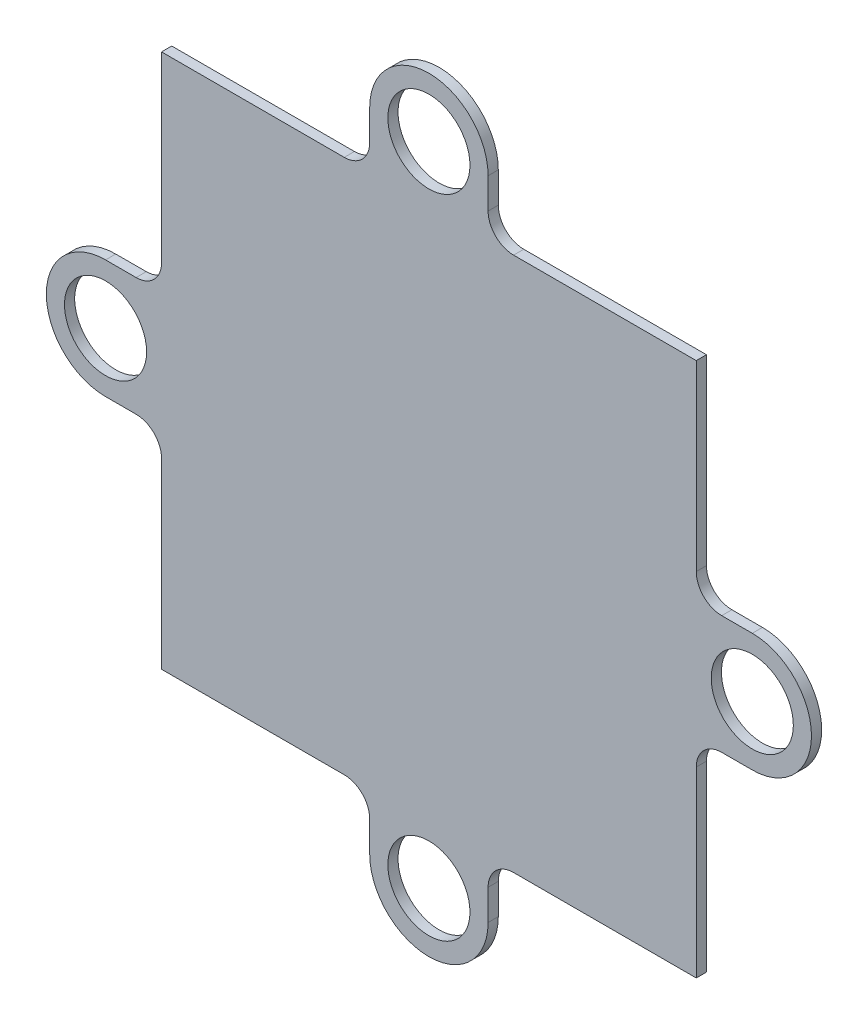
from build123d import *

# Parameters (mm, degrees)
SKETCH1_R           = 3.225
BOSS_EXTRUDE1_DEPTH = 0.8


with BuildPart() as part:
    # Sketch1 → Boss-Extrude1 (new body)
    with BuildSketch(Plane.XY):
        with BuildLine():
            ThreePointArc((4.65, 25.4), (0, 30.05), (-4.65, 25.4))
            Line((-4.65, 25.4), (-4.65, 23))
            ThreePointArc((-4.65, 23), (-5.235786438, 21.585786438), (-6.65, 21))
            Line((-6.65, 21), (-8.759132098, 21))
            Line((-8.759132098, 21), (-21, 21))
            Line((-21, 21), (-21, 7.133487824))
            Line((-21, 7.133487824), (-21, 6.65))
            ThreePointArc((-21, 6.65), (-21.585786438, 5.235786438), (-23, 4.65))
            Line((-23, 4.65), (-25.4, 4.65))
            ThreePointArc((-25.4, 4.65), (-30.05, 0), (-25.4, -4.65))
            Line((-25.4, -4.65), (-23, -4.65))
            ThreePointArc((-23, -4.65), (-21.585786438, -5.235786438), (-21, -6.65))
            Line((-21, -6.65), (-21, -8.759132098))
            Line((-21, -8.759132098), (-21, -21))
            Line((-21, -21), (-7.133487824, -21))
            Line((-7.133487824, -21), (-6.65, -21))
            ThreePointArc((-6.65, -21), (-5.235786438, -21.585786438), (-4.65, -23))
            Line((-4.65, -23), (-4.65, -25.4))
            ThreePointArc((-4.65, -25.4), (0, -30.05), (4.65, -25.4))
            Line((4.65, -25.4), (4.65, -23))
            ThreePointArc((4.65, -23), (5.235786438, -21.585786438), (6.65, -21))
            Line((6.65, -21), (8.759132098, -21))
            Line((8.759132098, -21), (21, -21))
            Line((21, -21), (21, -7.133487824))
            Line((21, -7.133487824), (21, -6.65))
            ThreePointArc((21, -6.65), (21.585786438, -5.235786438), (23, -4.65))
            Line((23, -4.65), (25.4, -4.65))
            ThreePointArc((25.4, -4.65), (30.05, 0), (25.4, 4.65))
            Line((25.4, 4.65), (23, 4.65))
            ThreePointArc((23, 4.65), (21.585786438, 5.235786438), (21, 6.65))
            Line((21, 6.65), (21, 8.759132098))
            Line((21, 8.759132098), (21, 21))
            Line((21, 21), (7.133487824, 21))
            Line((7.133487824, 21), (6.65, 21))
            ThreePointArc((6.65, 21), (5.235786438, 21.585786438), (4.65, 23))
            Line((4.65, 23), (4.65, 25.4))
        make_face()
        with Locations((0, -25.4)):
            Circle(SKETCH1_R, mode=Mode.SUBTRACT)
        with Locations((25.4, 0)):
            Circle(SKETCH1_R, mode=Mode.SUBTRACT)
        with Locations((-25.4, 0)):
            Circle(SKETCH1_R, mode=Mode.SUBTRACT)
        with Locations((0, 25.4)):
            Circle(SKETCH1_R, mode=Mode.SUBTRACT)
    extrude(amount=BOSS_EXTRUDE1_DEPTH)


solid = part.part
